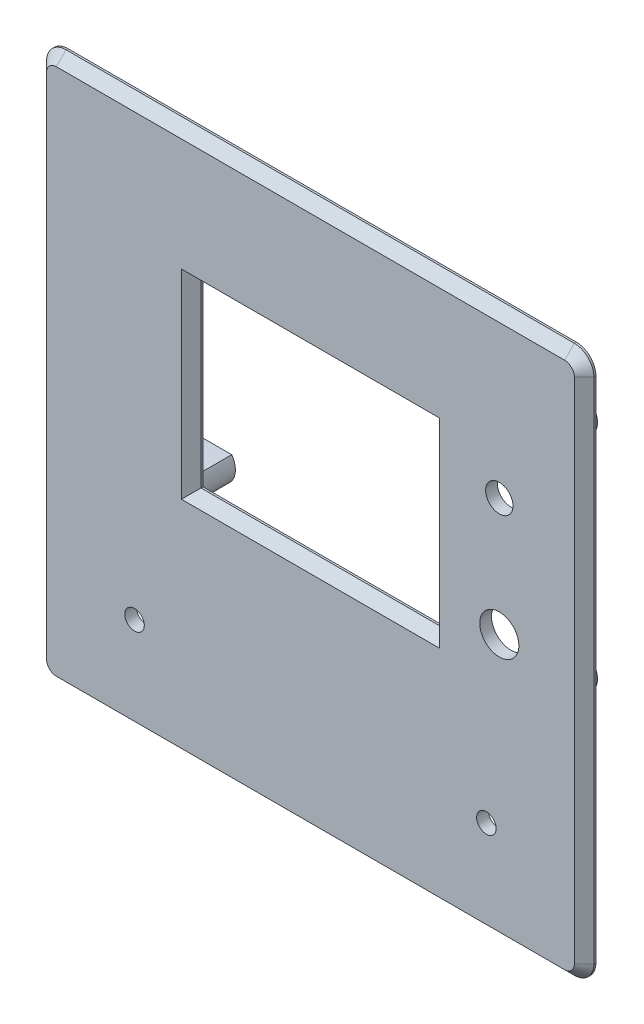
from build123d import *

# Parameters (mm, degrees)
SKETCH1_W           = 140
SKETCH1_H           = 140
SKETCH1_R           = 3.5
SKETCH1_R_2         = 2
SKETCH1_R_3         = 5
SKETCH1_R_4         = 2.5
SKETCH1_W_2         = 61
SKETCH1_H_2         = 46
BOSS_EXTRUDE1_DEPTH = 3
CHAMFER1_SIZE       = 2.5
FILLET1_R           = 5
CHAMFER2_SIZE       = 2.5
SKETCH2_R           = 5
BOSS_EXTRUDE3_DEPTH = 13.3
CHAMFER3_SIZE       = 3
SKETCH4_R           = 2
CUT_EXTRUDE1_DEPTH  = 8
SKETCH6_W           = 89.583277887
SKETCH6_H           = 51
CUT_EXTRUDE2_DEPTH  = 13.3
SKETCH7_R           = 4.27453946
SKETCH7_R_2         = 4.288417291
SKETCH7_R_3         = 5.40642801
SKETCH7_R_4         = 4.2459997
BOSS_EXTRUDE4_DEPTH = 3


with BuildPart() as part:
    # Sketch1 → Boss-Extrude1 (new body)
    with BuildSketch(Plane.XY):
        with Locations((0, -13.199218639)):
            Rectangle(SKETCH1_W, SKETCH1_H)
        with Locations((48.3, 15.4)):
            Circle(SKETCH1_R, mode=Mode.SUBTRACT)
        with Locations((-40.5, 28.4)):
            Circle(SKETCH1_R_2, mode=Mode.SUBTRACT)
        with Locations((52.1, 28.4)):
            Circle(SKETCH1_R_2, mode=Mode.SUBTRACT)
        with Locations((52.1, -28.4)):
            Circle(SKETCH1_R_2, mode=Mode.SUBTRACT)
        with Locations((-40.5, -28.4)):
            Circle(SKETCH1_R_2, mode=Mode.SUBTRACT)
        with Locations((48.3, -14.8)):
            Circle(SKETCH1_R_3, mode=Mode.SUBTRACT)
        with Locations((45, -58.199218639)):
            Circle(SKETCH1_R_4, mode=Mode.SUBTRACT)
        with Locations((-45, -58.199218639)):
            Circle(SKETCH1_R_4, mode=Mode.SUBTRACT)
        Rectangle(SKETCH1_W_2, SKETCH1_H_2, mode=Mode.SUBTRACT)
    extrude(amount=BOSS_EXTRUDE1_DEPTH)

    # Chamfer1
    chamfer1_edges = [part.edges().sort_by_distance(p)[0] for p in [
        (30.5, 0, 3),
        (0, 23, 3),
        (-30.5, 0, 3),
        (0, -23, 3),
    ]]
    chamfer(chamfer1_edges, length=CHAMFER1_SIZE)

    # Fillet1
    fillet1_edges = [part.edges().sort_by_distance(p)[0] for p in [
        (70, -83.199218639, 1.5),
        (-70, -83.199218639, 1.5),
        (-70, 56.800781361, 1.5),
        (70, 56.800781361, 1.5),
    ]]
    fillet(fillet1_edges, radius=FILLET1_R)

    # Chamfer2
    chamfer2_edges = [part.edges().sort_by_distance(p)[0] for p in [
        (-70, -13.199218639, 3),
        (0, 56.800781361, 3),
        (70, -13.199218639, 3),
        (0, -83.199218639, 3),
        (-68.535533906, -81.734752545, 3),
        (68.535533906, -81.734752545, 3),
        (68.535533906, 55.336315267, 3),
        (-68.535533906, 55.336315267, 3),
    ]]
    chamfer(chamfer2_edges, length=CHAMFER2_SIZE)

    # Sketch2 → Boss-Extrude3 (add)
    with BuildSketch(Plane.XY):
        with Locations((52.1, 28.4)):
            Circle(SKETCH2_R)
        with Locations((52.1, -28.4)):
            Circle(SKETCH2_R)
        with Locations((-40.5, 28.4)):
            Circle(SKETCH2_R)
        with Locations((-40.5, -28.4)):
            Circle(SKETCH2_R)
    extrude(amount=-BOSS_EXTRUDE3_DEPTH)

    # Chamfer3
    chamfer3_edges = [part.edges().sort_by_distance(p)[0] for p in [
        (47.1, 28.4, 0),
        (47.1, -28.4, 0),
        (-45.5, 28.4, 0),
        (-45.5, -28.4, 0),
    ]]
    chamfer(chamfer3_edges, length=CHAMFER3_SIZE)

    # Sketch4 → Cut-Extrude1 (cut)
    with BuildSketch(Plane(origin=(0, 0, -13.3), x_dir=(-1, 0, 0), z_dir=(0, 0, -1))):
        with Locations((-52.1, 28.4)):
            Circle(SKETCH4_R)
        with Locations((40.5, 28.4)):
            Circle(SKETCH4_R)
        with Locations((40.5, -28.4)):
            Circle(SKETCH4_R)
        with Locations((-52.1, -28.4)):
            Circle(SKETCH4_R)
    extrude(amount=-CUT_EXTRUDE1_DEPTH, mode=Mode.SUBTRACT)

    # Sketch6 → Cut-Extrude2 (cut)
    with BuildSketch(Plane(origin=(0, 0, -13.3), x_dir=(-1, 0, 0), z_dir=(0, 0, -1))):
        with Locations((25.208361056, 0)):
            Rectangle(SKETCH6_W, SKETCH6_H)
    extrude(amount=-CUT_EXTRUDE2_DEPTH, mode=Mode.SUBTRACT)

    # Sketch7 → Boss-Extrude4 (add)
    with BuildSketch(Plane.XY.offset(3)):
        with Locations((-40.5, 28.4)):
            Circle(SKETCH7_R)
        with Locations((-40.5, -28.4)):
            Circle(SKETCH7_R_2)
        with Locations((52.1, 28.4)):
            Circle(SKETCH7_R_3)
        with Locations((52.1, -28.4)):
            Circle(SKETCH7_R_4)
    extrude(amount=-BOSS_EXTRUDE4_DEPTH)


solid = part.part
